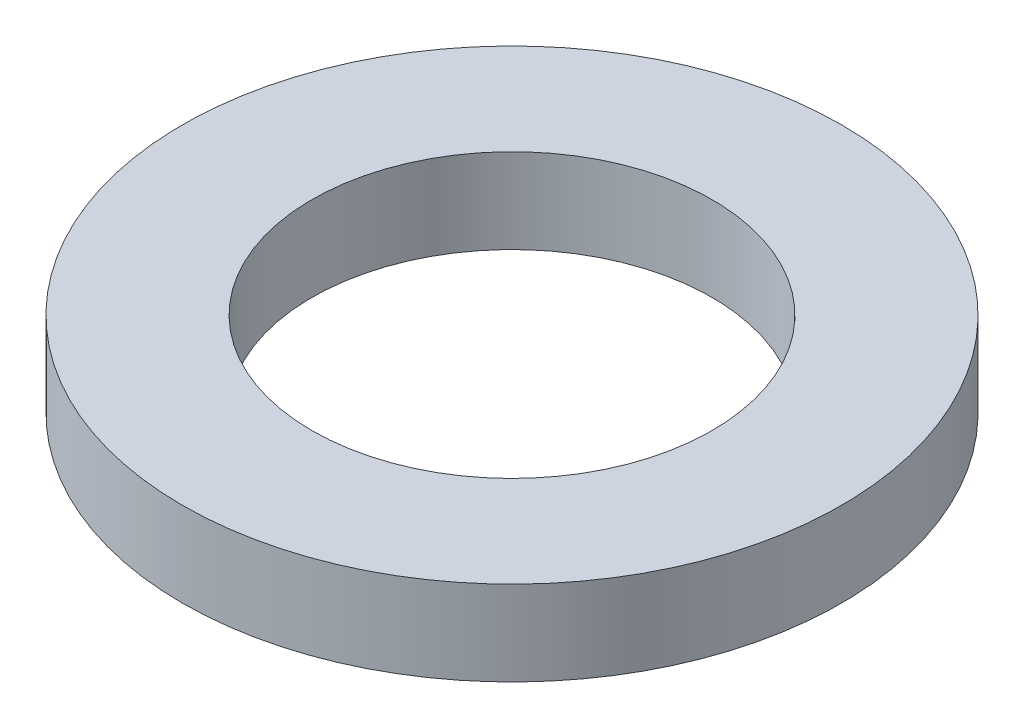
from build123d import *

# Parameters (mm, degrees)
SKETCH1_R           = 7
SKETCH1_R_2         = 4.25
BOSS_EXTRUDE1_DEPTH = 1.8


with BuildPart() as part:
    # Sketch1 → Boss-Extrude1 (new body)
    with BuildSketch(Plane(origin=(0, 0, 0), x_dir=(1, 0, 0), z_dir=(0, 1, 0))):
        Circle(SKETCH1_R)
        Circle(SKETCH1_R_2, mode=Mode.SUBTRACT)
    extrude(amount=BOSS_EXTRUDE1_DEPTH)


solid = part.part
